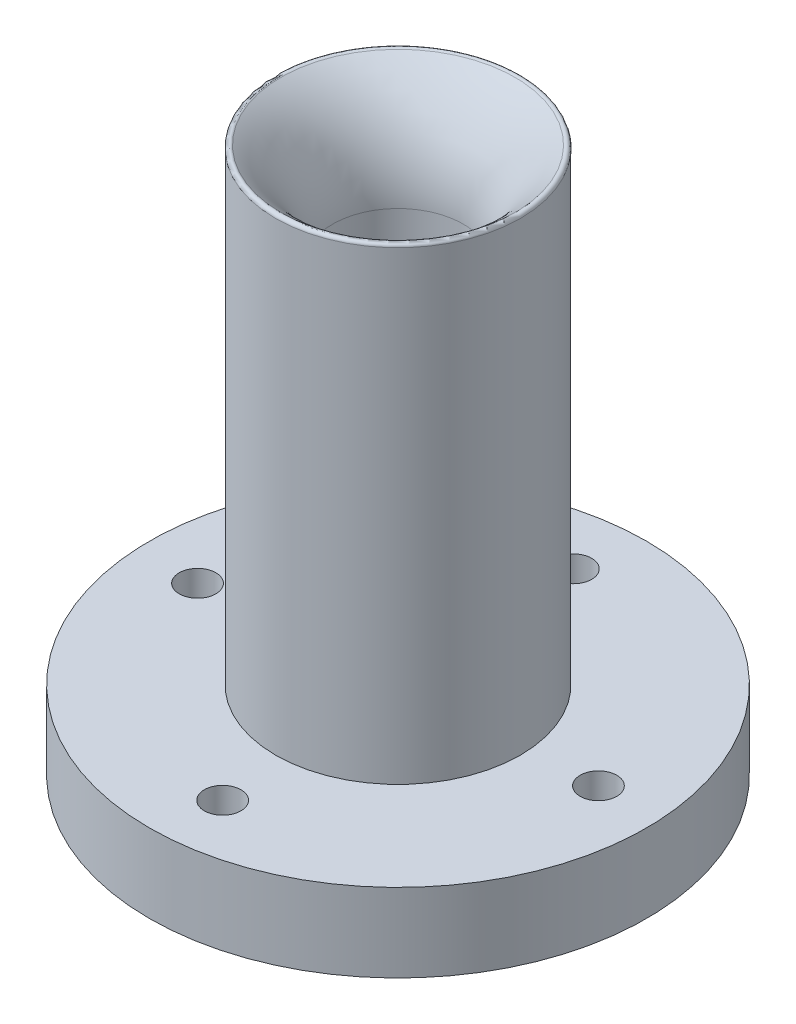
from build123d import *

# Parameters (mm, degrees)
SKETCH2_R          = 3.5
CUT_EXTRUDE1_DEPTH = 20


with BuildPart() as part:
    # Sketch1 → Revolve1 (revolve)
    with BuildSketch(Plane.XY):
        with BuildLine():
            Line((12.5, -14.9725871), (17.43319678, -14.9725871))
            Line((17.43319678, -14.9725871), (47.5, -14.9725871))
            Line((47.5, -14.9725871), (47.5, 0.0274129))
            Line((47.5, 0.0274129), (23.392075087, 0.0274129))
            Line((23.392075087, 0.0274129), (23.392075087, 88.874931748))
            ThreePointArc((23.392075087, 88.874931748), (23.040193106, 89.436291225), (22.381592941, 89.364241145))
            ThreePointArc((22.381592941, 89.364241145), (15.113172999, 80.869909317), (12.5, 70))
            Line((12.5, 70), (12.5, 0))
            Line((12.5, 0), (0, 0))
            Line((0, 0), (0, -14.9725871))
            Line((0, -14.9725871), (12.5, -14.9725871))
        make_face()
    revolve(axis=Axis((0, 0, 0), (0, -1, 0)))

    # Sketch2 → Cut-Extrude1 (cut)
    with BuildSketch(Plane(origin=(0, 0.0274129, 0), x_dir=(1, 0, 0), z_dir=(0, 1, 0))):
        with Locations((-2.39741815, 35.920083327)):
            Circle(SKETCH2_R)
        with Locations((-35.920083327, -2.39741815)):
            Circle(SKETCH2_R)
        with Locations((2.39741815, -35.920083327)):
            Circle(SKETCH2_R)
        with Locations((35.920083327, 2.39741815)):
            Circle(SKETCH2_R)
    extrude(amount=-CUT_EXTRUDE1_DEPTH, mode=Mode.SUBTRACT)


solid = part.part
